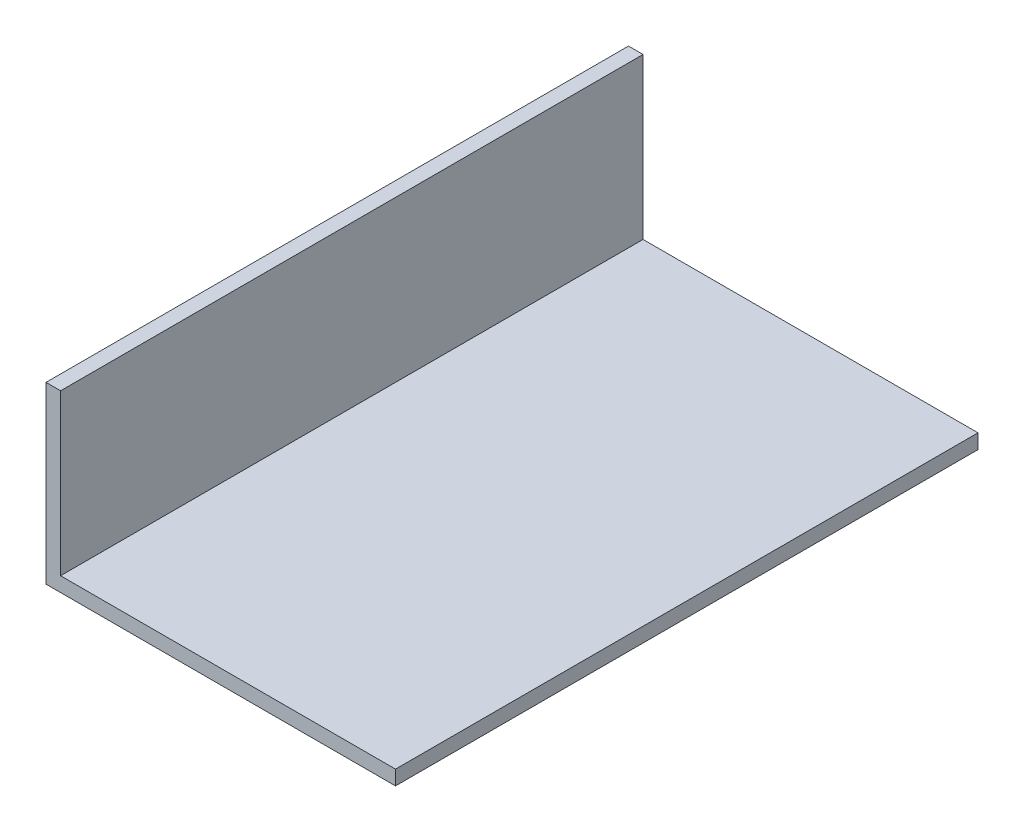
from build123d import *

# Parameters (mm, degrees)
BOSS_EXTRUDE1_DEPTH = 127


with BuildPart() as part:
    # Sketch1 → Boss-Extrude1 (new body)
    with BuildSketch(Plane.XY):
        Polygon((0, 0), (76.2, 0), (76.2, 3.175), (3.175, 3.175), (3.175, 38.1), (0, 38.1), align=None)
    extrude(amount=BOSS_EXTRUDE1_DEPTH)


solid = part.part
